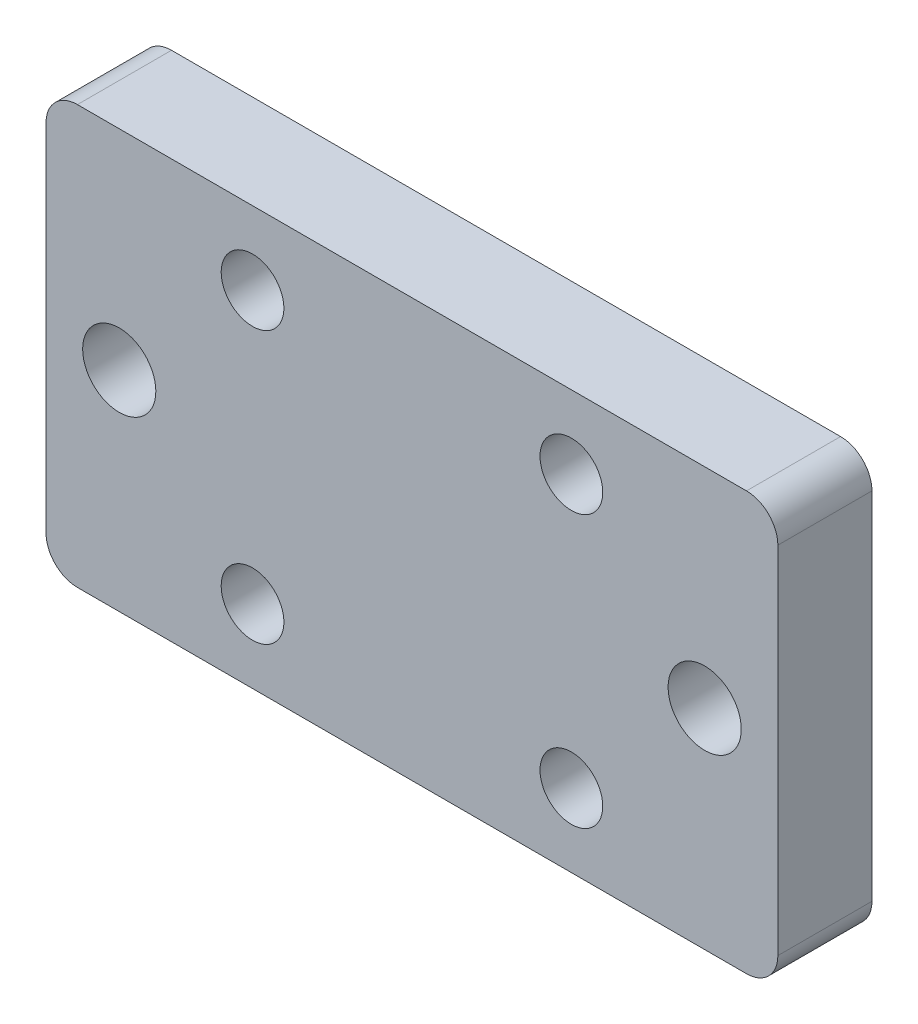
from build123d import *

# Parameters (mm, degrees)
ESQUISSE1_W                  = 70
ESQUISSE1_H                  = 40
BOSS_EXTRU_1_DEPTH           = 9
ESQUISSE2_R                  = 3
ESQUISSE2_R_2                = 3.5
ENL_V_MAT_EXTRU_1_DEPTH      = 1
ENL_V_MAT_EXTRU_1_DEPTH_BACK = 10
CONG_1_R                     = 3


with BuildPart() as part:
    # Esquisse1 → Boss.-Extru.1 (new body)
    with BuildSketch(Plane.XY):
        with Locations((35, 20)):
            Rectangle(ESQUISSE1_W, ESQUISSE1_H)
    extrude(amount=BOSS_EXTRU_1_DEPTH)

    # Esquisse2 → Enlèv. mat.-Extru.1 (cut, two sides)
    with BuildSketch(Plane.XY.offset(9)) as enl_v_mat_extru_1_sk:
        with Locations((19.75, 33)):
            Circle(ESQUISSE2_R)
        with Locations((50.25, 33)):
            Circle(ESQUISSE2_R)
        with Locations((50.25, 7)):
            Circle(ESQUISSE2_R)
        with Locations((19.75, 7)):
            Circle(ESQUISSE2_R)
        with Locations((7, 20)):
            Circle(ESQUISSE2_R_2)
        with Locations((63, 20)):
            Circle(ESQUISSE2_R_2)
    extrude(amount=ENL_V_MAT_EXTRU_1_DEPTH, mode=Mode.SUBTRACT)
    extrude(enl_v_mat_extru_1_sk.sketch, amount=-ENL_V_MAT_EXTRU_1_DEPTH_BACK, mode=Mode.SUBTRACT)

    # Congé1
    cong_1_edges = [part.edges().sort_by_distance(p)[0] for p in [
        (0, 40, 4.5),
        (70, 40, 4.5),
        (70, 0, 4.5),
        (0, 0, 4.5),
    ]]
    fillet(cong_1_edges, radius=CONG_1_R)


solid = part.part
